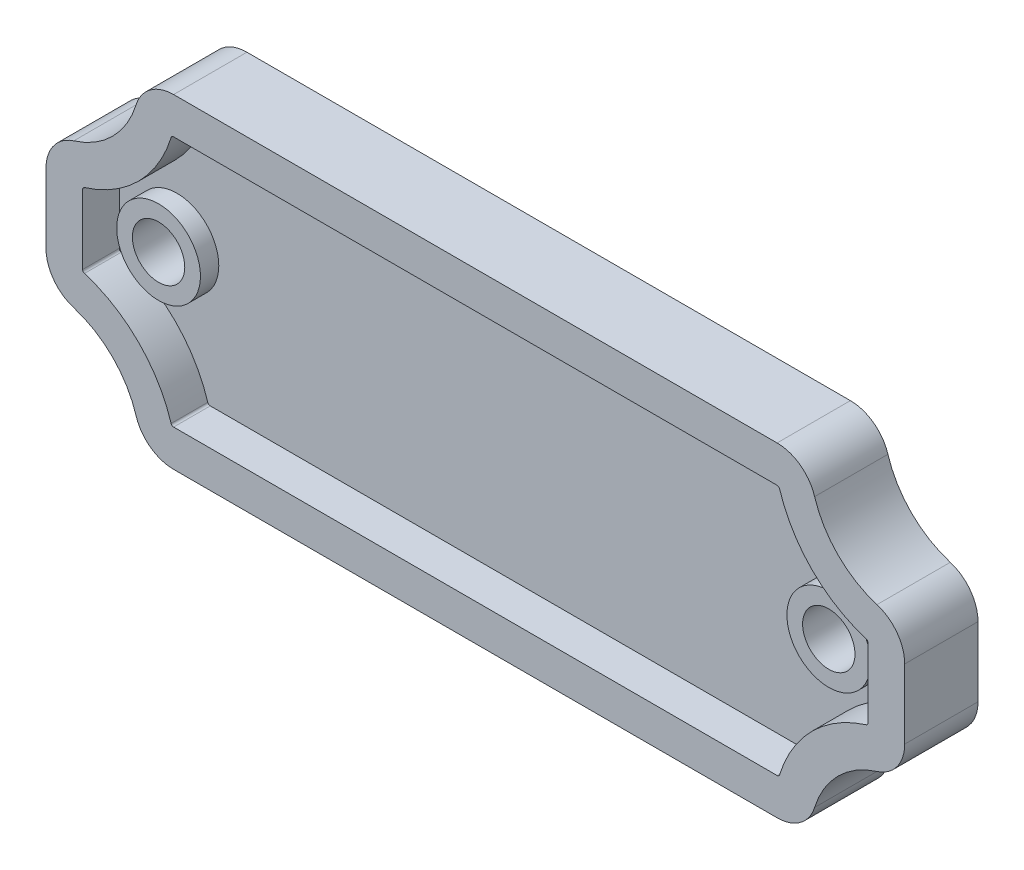
from build123d import *

# Parameters (mm, degrees)
BOSS_EXTRUDE3_DEPTH        = 5.25
BOSS_EXTRUDE3_DEPTH_BACK   = 1.75
SKETCH8_R                  = 4
SKETCH8_R_2                = 2.5
BOSS_EXTRUDE3_2_DEPTH      = 5.25
BOSS_EXTRUDE3_2_DEPTH_BACK = 1.75
SKETCH8_4_R                = 4
BOSS_EXTRUDE4_DEPTH        = 3.5
BOSS_EXTRUDE5_DEPTH        = 7


with BuildPart() as part:
    # Sketch8 → Boss-Extrude3 (new, two sides: drawn at the far end of the back side and taken through both)
    with BuildSketch(Plane.XY.offset(-BOSS_EXTRUDE3_DEPTH_BACK)):
        with Locations((9, 0)):
            Circle(SKETCH8_R)
        with Locations((9, 0)):
            Circle(SKETCH8_R_2, mode=Mode.SUBTRACT)
    extrude(amount=BOSS_EXTRUDE3_DEPTH + BOSS_EXTRUDE3_DEPTH_BACK)


with BuildPart() as body_2:
    # Sketch8 → Boss-Extrude3 2 (new, two sides: drawn at the far end of the back side and taken through both)
    with BuildSketch(Plane.XY.offset(-BOSS_EXTRUDE3_2_DEPTH_BACK)):
        with Locations((73, 0)):
            Circle(SKETCH8_R)
        with Locations((73, 0)):
            Circle(SKETCH8_R_2, mode=Mode.SUBTRACT)
    extrude(amount=BOSS_EXTRUDE3_2_DEPTH + BOSS_EXTRUDE3_2_DEPTH_BACK)


with BuildPart() as body_3:
    # Sketch8_4 → Boss-Extrude4 (new body)
    with BuildSketch(Plane.XY):
        with BuildLine():
            Line((3.5, 3.313942393), (3.5, -3.313942393))
            ThreePointArc((3.5, -3.313942393), (3.548900083, -3.462464524), (3.676470588, -3.552884699))
            ThreePointArc((3.676470588, -3.552884699), (8.838834765, -6.661165235), (11.947115301, -11.823529412))
            ThreePointArc((11.947115301, -11.823529412), (12.037535476, -11.951099917), (12.186057607, -12))
            Line((12.186057607, -12), (69.813942393, -12))
            ThreePointArc((69.813942393, -12), (69.962464524, -11.951099917), (70.052884699, -11.823529412))
            ThreePointArc((70.052884699, -11.823529412), (73.161165235, -6.661165235), (78.323529412, -3.552884699))
            ThreePointArc((78.323529412, -3.552884699), (78.451099917, -3.462464524), (78.5, -3.313942393))
            Line((78.5, -3.313942393), (78.5, 3.313942393))
            ThreePointArc((78.5, 3.313942393), (78.451099917, 3.462464524), (78.323529412, 3.552884699))
            ThreePointArc((78.323529412, 3.552884699), (73.161165235, 6.661165235), (70.052884699, 11.823529412))
            ThreePointArc((70.052884699, 11.823529412), (69.962464524, 11.951099917), (69.813942393, 12))
            Line((69.813942393, 12), (12.186057607, 12))
            ThreePointArc((12.186057607, 12), (12.037535476, 11.951099917), (11.947115301, 11.823529412))
            ThreePointArc((11.947115301, 11.823529412), (8.838834765, 6.661165235), (3.676470588, 3.552884699))
            ThreePointArc((3.676470588, 3.552884699), (3.548900083, 3.462464524), (3.5, 3.313942393))
        make_face()
        with Locations((9, 0)):
            Circle(SKETCH8_4_R, mode=Mode.SUBTRACT)
        with Locations((73, 0)):
            Circle(SKETCH8_4_R, mode=Mode.SUBTRACT)
    extrude(amount=BOSS_EXTRUDE4_DEPTH)


with BuildPart() as body_4:
    # Sketch8_6 → Boss-Extrude5 (new body)
    with BuildSketch(Plane.XY):
        with BuildLine():
            ThreePointArc((0, -3.313942393), (0.73350125, -5.541774365), (2.647058824, -6.898076983))
            ThreePointArc((2.647058824, -6.898076983), (6.363961031, -9.136038969), (8.601923017, -12.852941176))
            ThreePointArc((8.601923017, -12.852941176), (9.958225635, -14.76649875), (12.186057607, -15.5))
            Line((12.186057607, -15.5), (69.813942393, -15.5))
            ThreePointArc((69.813942393, -15.5), (72.041774365, -14.76649875), (73.398076983, -12.852941176))
            ThreePointArc((73.398076983, -12.852941176), (75.636038969, -9.136038969), (79.352941176, -6.898076983))
            ThreePointArc((79.352941176, -6.898076983), (81.26649875, -5.541774365), (82, -3.313942393))
            Line((82, -3.313942393), (82, 3.313942393))
            ThreePointArc((82, 3.313942393), (81.26649875, 5.541774365), (79.352941176, 6.898076983))
            ThreePointArc((79.352941176, 6.898076983), (75.636038969, 9.136038969), (73.398076983, 12.852941176))
            ThreePointArc((73.398076983, 12.852941176), (72.041774365, 14.76649875), (69.813942393, 15.5))
            Line((69.813942393, 15.5), (12.186057607, 15.5))
            ThreePointArc((12.186057607, 15.5), (9.958225635, 14.76649875), (8.601923017, 12.852941176))
            ThreePointArc((8.601923017, 12.852941176), (6.363961031, 9.136038969), (2.647058824, 6.898076983))
            ThreePointArc((2.647058824, 6.898076983), (0.73350125, 5.541774365), (0, 3.313942393))
            Line((0, 3.313942393), (0, -3.313942393))
        make_face()
        with BuildLine():
            Line((3.5, -3.313942393), (3.5, 3.313942393))
            ThreePointArc((3.5, 3.313942393), (3.548900083, 3.462464524), (3.676470588, 3.552884699))
            ThreePointArc((3.676470588, 3.552884699), (8.838834765, 6.661165235), (11.947115301, 11.823529412))
            ThreePointArc((11.947115301, 11.823529412), (12.037535476, 11.951099917), (12.186057607, 12))
            Line((12.186057607, 12), (69.813942393, 12))
            ThreePointArc((69.813942393, 12), (69.962464524, 11.951099917), (70.052884699, 11.823529412))
            ThreePointArc((70.052884699, 11.823529412), (73.161165235, 6.661165235), (78.323529412, 3.552884699))
            ThreePointArc((78.323529412, 3.552884699), (78.451099917, 3.462464524), (78.5, 3.313942393))
            Line((78.5, 3.313942393), (78.5, -3.313942393))
            ThreePointArc((78.5, -3.313942393), (78.451099917, -3.462464524), (78.323529412, -3.552884699))
            ThreePointArc((78.323529412, -3.552884699), (73.161165235, -6.661165235), (70.052884699, -11.823529412))
            ThreePointArc((70.052884699, -11.823529412), (69.962464524, -11.951099917), (69.813942393, -12))
            Line((69.813942393, -12), (12.186057607, -12))
            ThreePointArc((12.186057607, -12), (12.037535476, -11.951099917), (11.947115301, -11.823529412))
            ThreePointArc((11.947115301, -11.823529412), (8.838834765, -6.661165235), (3.676470588, -3.552884699))
            ThreePointArc((3.676470588, -3.552884699), (3.548900083, -3.462464524), (3.5, -3.313942393))
        make_face(mode=Mode.SUBTRACT)
    extrude(amount=BOSS_EXTRUDE5_DEPTH)


solid = Compound([part.part, body_2.part, body_3.part, body_4.part])
